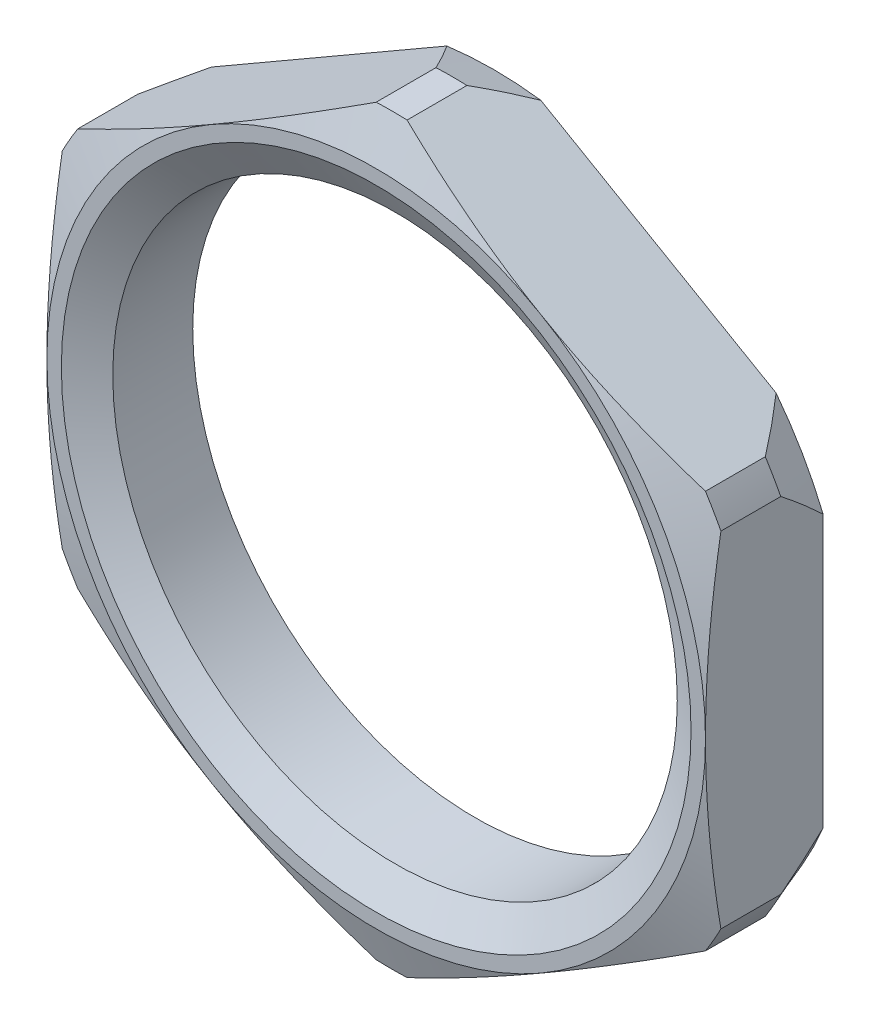
from build123d import *

# Parameters (mm, degrees)
BOSS_EXTRUDE1_DEPTH   = 2.5
HOLE1_D               = 12
HOLE1_DEPTH           = 2.5
CHAMFER1_SIZE         = 0.9
CHAMFER1_SIZE2        = 0.327573212
CHAMFER1_PART_2_SIZE  = 0.9
CHAMFER1_PART_2_SIZE2 = 0.327573212
CHAMFER1_PART_3_SIZE  = 0.9
CHAMFER1_PART_3_SIZE2 = 0.327573212
CHAMFER1_PART_4_SIZE  = 0.9
CHAMFER1_PART_4_SIZE2 = 0.327573212
CHAMFER1_PART_5_SIZE  = 0.9
CHAMFER1_PART_5_SIZE2 = 0.327573212
CHAMFER1_PART_6_SIZE  = 0.9
CHAMFER1_PART_6_SIZE2 = 0.327573212
CHAMFER1_PART_7_SIZE  = 0.9
CHAMFER1_PART_7_SIZE2 = 0.327573212
CHAMFER2_SIZE         = 0.692820323
CHAMFER2_SIZE2        = 0.400000001
CHAMFER3_SIZE         = 0.692820323
CHAMFER3_SIZE2        = 0.400000001


with BuildPart() as part:
    # Sketch1 → Boss-Extrude1 (new body)
    with BuildSketch(Plane(origin=(0, 0, 6), x_dir=(-1, 0, 0), z_dir=(0, 0, -1))):
        with BuildLine():
            Line((-7, 3.661966685), (-7, -3.661966685))
            ThreePointArc((-7, -3.661966685), (-6.84160069, -3.95), (-6.671356177, -4.231194484))
            Line((-6.671356177, -4.231194484), (-0.328643823, -7.893161169))
            ThreePointArc((-0.328643823, -7.893161169), (0, -7.9), (0.328643823, -7.893161169))
            Line((0.328643823, -7.893161169), (6.671356177, -4.231194484))
            ThreePointArc((6.671356177, -4.231194484), (6.84160069, -3.95), (7, -3.661966685))
            Line((7, -3.661966685), (7, 3.661966685))
            ThreePointArc((7, 3.661966685), (6.84160069, 3.95), (6.671356177, 4.231194484))
            Line((6.671356177, 4.231194484), (0.328643823, 7.893161169))
            ThreePointArc((0.328643823, 7.893161169), (0, 7.9), (-0.328643823, 7.893161169))
            Line((-0.328643823, 7.893161169), (-6.671356177, 4.231194484))
            ThreePointArc((-6.671356177, 4.231194484), (-6.84160069, 3.95), (-7, 3.661966685))
        make_face()
    extrude(amount=-BOSS_EXTRUDE1_DEPTH)

    # Hole1
    with Locations(Plane(origin=(0, 0, 6), x_dir=(-1, 0, 0), z_dir=(0, 0, -1))):
        with Locations((0, 0)):
            Hole(HOLE1_D / 2, depth=HOLE1_DEPTH)

    # Chamfer1
    chamfer1_edges = [part.edges().sort_by_distance(p)[0] for p in [
        (0, -7.9, 8.5),
        (-6.84160069, 3.95, 8.5),
        (6.84160069, 3.95, 8.5),
        (6.84160069, -3.95, 8.5),
        (0, 7.9, 8.5),
        (-6.84160069, -3.95, 8.5),
    ]]
    chamfer1_side = [part.faces().sort_by_distance(p)[0] for p in [
        (3.394449064, 5.879358243, 8.5),
    ]]
    chamfer(chamfer1_edges, length=CHAMFER1_SIZE, length2=CHAMFER1_SIZE2, reference=chamfer1_side[0])

    # Chamfer1 part 2
    chamfer1_part_2_edges = [part.edges().sort_by_distance(p)[0] for p in [
        (6.84160069, 3.95, 6),
    ]]
    chamfer1_part_2_side = [part.faces().sort_by_distance(p)[0] for p in [
        (6.84160069, 3.95, 7.25),
    ]]
    chamfer(chamfer1_part_2_edges, length=CHAMFER1_PART_2_SIZE, length2=CHAMFER1_PART_2_SIZE2, reference=chamfer1_part_2_side[0])

    # Chamfer1 part 3
    chamfer1_part_3_edges = [part.edges().sort_by_distance(p)[0] for p in [
        (0, 7.9, 6),
    ]]
    chamfer1_part_3_side = [part.faces().sort_by_distance(p)[0] for p in [
        (0, 7.9, 7.25),
    ]]
    chamfer(chamfer1_part_3_edges, length=CHAMFER1_PART_3_SIZE, length2=CHAMFER1_PART_3_SIZE2, reference=chamfer1_part_3_side[0])

    # Chamfer1 part 4
    chamfer1_part_4_edges = [part.edges().sort_by_distance(p)[0] for p in [
        (-6.84160069, 3.95, 6),
    ]]
    chamfer1_part_4_side = [part.faces().sort_by_distance(p)[0] for p in [
        (-6.84160069, 3.95, 7.25),
    ]]
    chamfer(chamfer1_part_4_edges, length=CHAMFER1_PART_4_SIZE, length2=CHAMFER1_PART_4_SIZE2, reference=chamfer1_part_4_side[0])

    # Chamfer1 part 5
    chamfer1_part_5_edges = [part.edges().sort_by_distance(p)[0] for p in [
        (-6.84160069, -3.95, 6),
    ]]
    chamfer1_part_5_side = [part.faces().sort_by_distance(p)[0] for p in [
        (-6.84160069, -3.95, 7.25),
    ]]
    chamfer(chamfer1_part_5_edges, length=CHAMFER1_PART_5_SIZE, length2=CHAMFER1_PART_5_SIZE2, reference=chamfer1_part_5_side[0])

    # Chamfer1 part 6
    chamfer1_part_6_edges = [part.edges().sort_by_distance(p)[0] for p in [
        (0, -7.9, 6),
    ]]
    chamfer1_part_6_side = [part.faces().sort_by_distance(p)[0] for p in [
        (0, -7.9, 7.25),
    ]]
    chamfer(chamfer1_part_6_edges, length=CHAMFER1_PART_6_SIZE, length2=CHAMFER1_PART_6_SIZE2, reference=chamfer1_part_6_side[0])

    # Chamfer1 part 7
    chamfer1_part_7_edges = [part.edges().sort_by_distance(p)[0] for p in [
        (6.84160069, -3.95, 6),
    ]]
    chamfer1_part_7_side = [part.faces().sort_by_distance(p)[0] for p in [
        (6.84160069, -3.95, 7.25),
    ]]
    chamfer(chamfer1_part_7_edges, length=CHAMFER1_PART_7_SIZE, length2=CHAMFER1_PART_7_SIZE2, reference=chamfer1_part_7_side[0])

    # Chamfer2
    chamfer2_edges = [part.edges().sort_by_distance(p)[0] for p in [
        (-6, 0, 6),
    ]]
    chamfer2_side = [part.faces().sort_by_distance(p)[0] for p in [
        (3.396877913, -5.883565133, 6),
    ]]
    chamfer(chamfer2_edges, length=CHAMFER2_SIZE, length2=CHAMFER2_SIZE2, reference=chamfer2_side[0])

    # Chamfer3
    chamfer3_edges = [part.edges().sort_by_distance(p)[0] for p in [
        (-6, 0, 8.5),
    ]]
    chamfer3_side = [part.faces().sort_by_distance(p)[0] for p in [
        (3.401005054, 5.890713542, 8.5),
    ]]
    chamfer(chamfer3_edges, length=CHAMFER3_SIZE, length2=CHAMFER3_SIZE2, reference=chamfer3_side[0])


solid = part.part
